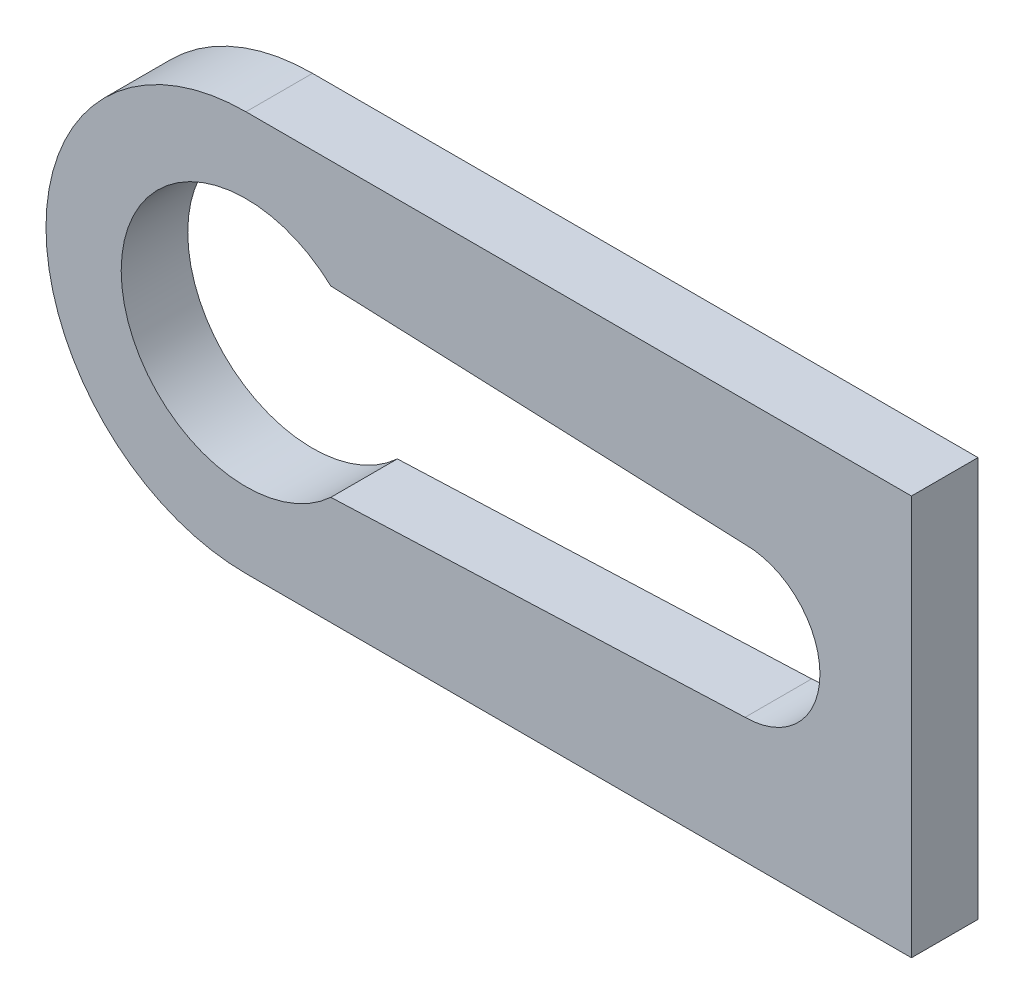
from build123d import *

# Parameters (mm, degrees)
BOSS_EXTRUDE1_DEPTH = 2


with BuildPart() as part:
    # Sketch1 → Boss-Extrude1 (new body)
    with BuildSketch(Plane.XY):
        with BuildLine():
            Line((5, 6.009754879), (-15, 6.009754879))
            ThreePointArc((-15, 6.009754879), (-21.009754879, 0), (-15, -6.009754879))
            Line((-15, -6.009754879), (5, -6.009754879))
            Line((5, -6.009754879), (5, 6.009754879))
        make_face()
        with BuildLine():
            ThreePointArc((-12.450490243, -2.75), (-18.75, 0), (-12.450490243, 2.75))
            Line((-12.450490243, 2.75), (0, 2.25))
            ThreePointArc((0, 2.25), (1.590990258, 1.590990258), (2.25, 0))
            ThreePointArc((2.25, 0), (1.590990258, -1.590990258), (0, -2.25))
            Line((0, -2.25), (-12.450490243, -2.75))
        make_face(mode=Mode.SUBTRACT)
    extrude(amount=BOSS_EXTRUDE1_DEPTH)


solid = part.part
